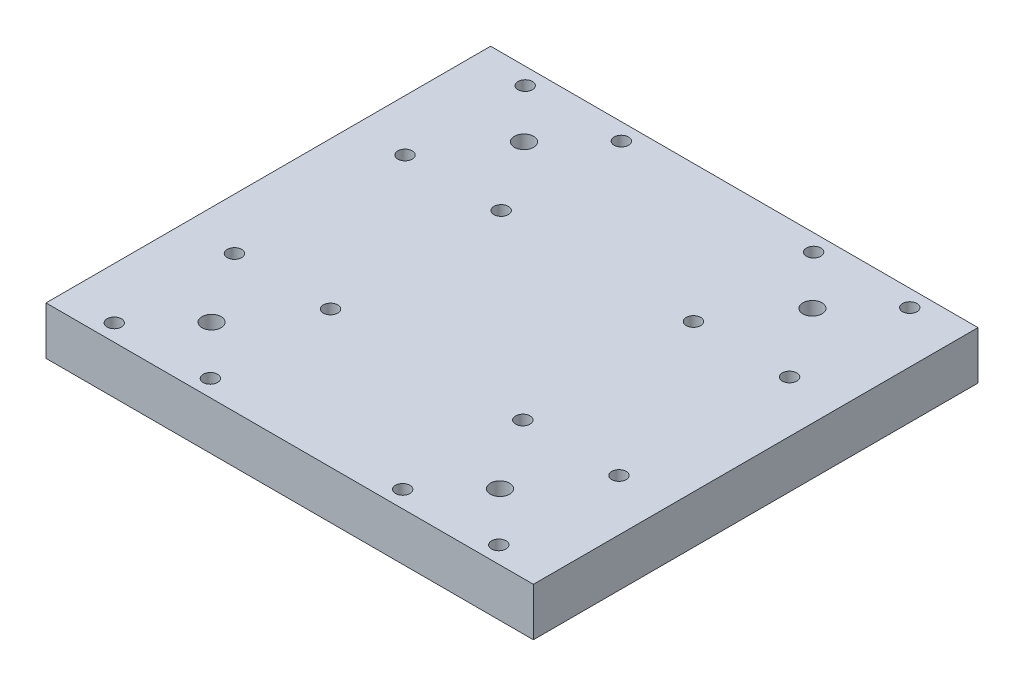
from build123d import *

# Parameters (mm, degrees)
SKETCH1_W           = 101.4
SKETCH1_H           = 92.5
SKETCH1_R           = 1.5
SKETCH1_R_2         = 2
BOSS_EXTRUDE1_DEPTH = 10


with BuildPart() as part:
    # Sketch1 → Boss-Extrude1 (new body)
    with BuildSketch(Plane(origin=(0, 0, 0), x_dir=(1, 0, 0), z_dir=(0, 1, 0))):
        Rectangle(SKETCH1_W, SKETCH1_H)
        with Locations((-40, 42.75)):
            Circle(SKETCH1_R, mode=Mode.SUBTRACT)
        with Locations((-20, 42.75)):
            Circle(SKETCH1_R, mode=Mode.SUBTRACT)
        with Locations((-20, 17.75)):
            Circle(SKETCH1_R, mode=Mode.SUBTRACT)
        with Locations((-40, 17.75)):
            Circle(SKETCH1_R, mode=Mode.SUBTRACT)
        with Locations((-40, -42.75)):
            Circle(SKETCH1_R, mode=Mode.SUBTRACT)
        with Locations((-20, -42.75)):
            Circle(SKETCH1_R, mode=Mode.SUBTRACT)
        with Locations((-20, -17.75)):
            Circle(SKETCH1_R, mode=Mode.SUBTRACT)
        with Locations((-40, -17.75)):
            Circle(SKETCH1_R, mode=Mode.SUBTRACT)
        with Locations((40, -17.75)):
            Circle(SKETCH1_R, mode=Mode.SUBTRACT)
        with Locations((20, -17.75)):
            Circle(SKETCH1_R, mode=Mode.SUBTRACT)
        with Locations((20, -42.75)):
            Circle(SKETCH1_R, mode=Mode.SUBTRACT)
        with Locations((40, -42.75)):
            Circle(SKETCH1_R, mode=Mode.SUBTRACT)
        with Locations((40, 17.75)):
            Circle(SKETCH1_R, mode=Mode.SUBTRACT)
        with Locations((20, 17.75)):
            Circle(SKETCH1_R, mode=Mode.SUBTRACT)
        with Locations((20, 42.75)):
            Circle(SKETCH1_R, mode=Mode.SUBTRACT)
        with Locations((40, 42.75)):
            Circle(SKETCH1_R, mode=Mode.SUBTRACT)
        with Locations((-30, 32.5)):
            Circle(SKETCH1_R_2, mode=Mode.SUBTRACT)
        with Locations((30, 32.5)):
            Circle(SKETCH1_R_2, mode=Mode.SUBTRACT)
        with Locations((30, -32.5)):
            Circle(SKETCH1_R_2, mode=Mode.SUBTRACT)
        with Locations((-30, -32.5)):
            Circle(SKETCH1_R_2, mode=Mode.SUBTRACT)
    extrude(amount=BOSS_EXTRUDE1_DEPTH)


solid = part.part
